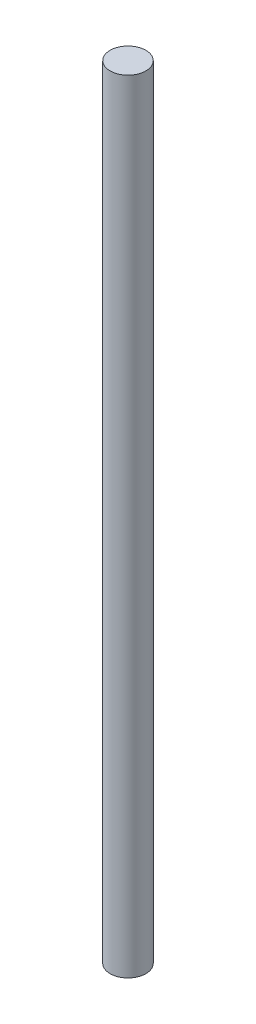
from build123d import *

# Parameters (mm, degrees)
CROQUIS1_R              = 4
SALIENTE_EXTRUIR1_DEPTH = 175


with BuildPart() as part:
    # Croquis1 → Saliente-Extruir1 (new body)
    with BuildSketch(Plane(origin=(0, 0, 0), x_dir=(1, 0, 0), z_dir=(0, 1, 0))):
        Circle(CROQUIS1_R)
    extrude(amount=SALIENTE_EXTRUIR1_DEPTH)


solid = part.part
